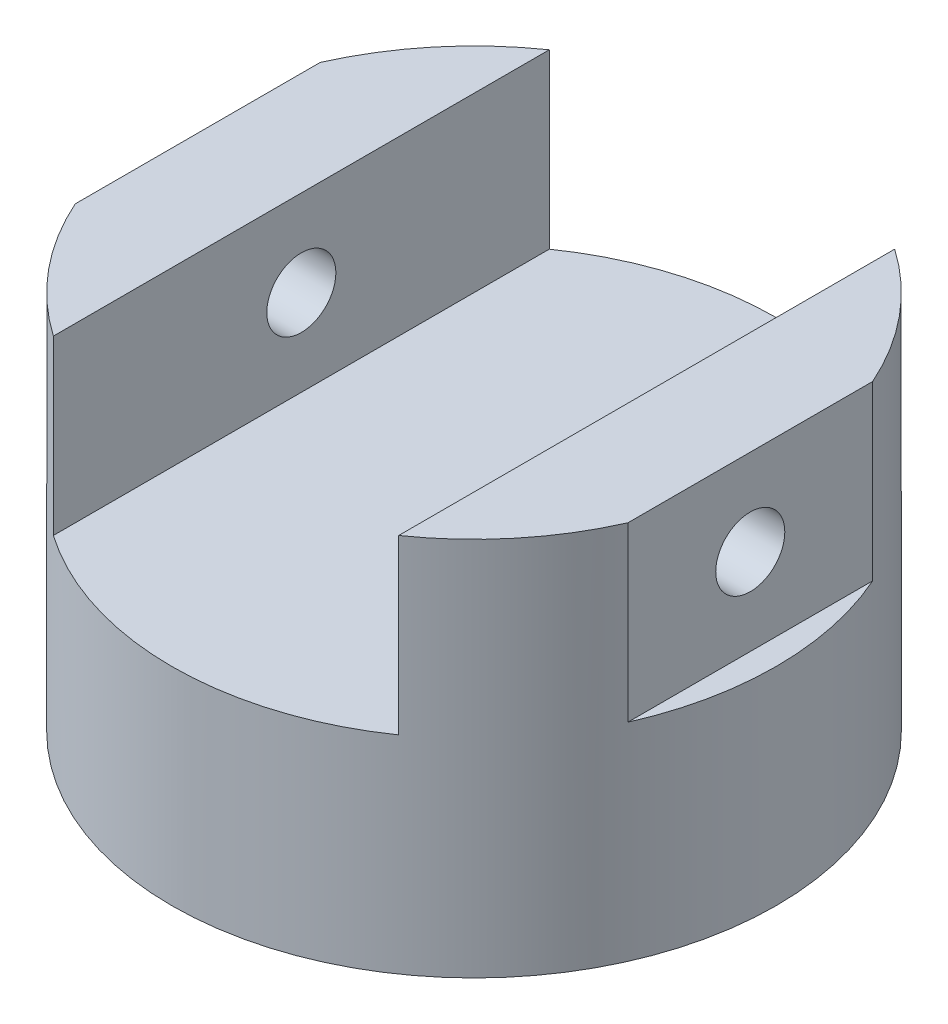
from build123d import *

# Parameters (mm, degrees)
ESBO_O2_W                  = 200
ESBO_O2_H                  = 100
ESBO_O2_W_2                = 15
CORTE_EXTRUS_O1_DEPTH      = 176
CORTE_EXTRUS_O1_DEPTH_BACK = 176
ESBO_O3_R                  = 20
CORTE_EXTRUS_O2_DEPTH      = 16
CORTE_EXTRUS_O2_DEPTH_BACK = 336


with BuildPart() as part:
    # Esboço1 → Revolução1 (revolve)
    with BuildSketch(Plane.XY):
        Polygon((0, 260), (175, 260), (175, 40), (75, 40), (75, 0), (0, 0), align=None)
    revolve(axis=Axis((0, 0, 0), (0, 1, 0)))

    # Esboço2 → Corte-extrusão1 (cut, two sides)
    with BuildSketch(Plane.XY) as corte_extrus_o1_sk:
        with Locations((0, 210)):
            Rectangle(ESBO_O2_W, ESBO_O2_H)
        with Locations((167.5, 210)):
            Rectangle(ESBO_O2_W_2, ESBO_O2_H)
        with Locations((-167.5, 210)):
            Rectangle(ESBO_O2_W_2, ESBO_O2_H)
    extrude(amount=CORTE_EXTRUS_O1_DEPTH, mode=Mode.SUBTRACT)
    extrude(corte_extrus_o1_sk.sketch, amount=-CORTE_EXTRUS_O1_DEPTH_BACK, mode=Mode.SUBTRACT)

    # Esboço3 → Corte-extrusão2 (cut, two sides)
    with BuildSketch(Plane(origin=(160, 0, 0), x_dir=(0, 0, -1), z_dir=(1, 0, 0))) as corte_extrus_o2_sk:
        with Locations((0, 210)):
            Circle(ESBO_O3_R)
    extrude(amount=CORTE_EXTRUS_O2_DEPTH, mode=Mode.SUBTRACT)
    extrude(corte_extrus_o2_sk.sketch, amount=-CORTE_EXTRUS_O2_DEPTH_BACK, mode=Mode.SUBTRACT)


solid = part.part
